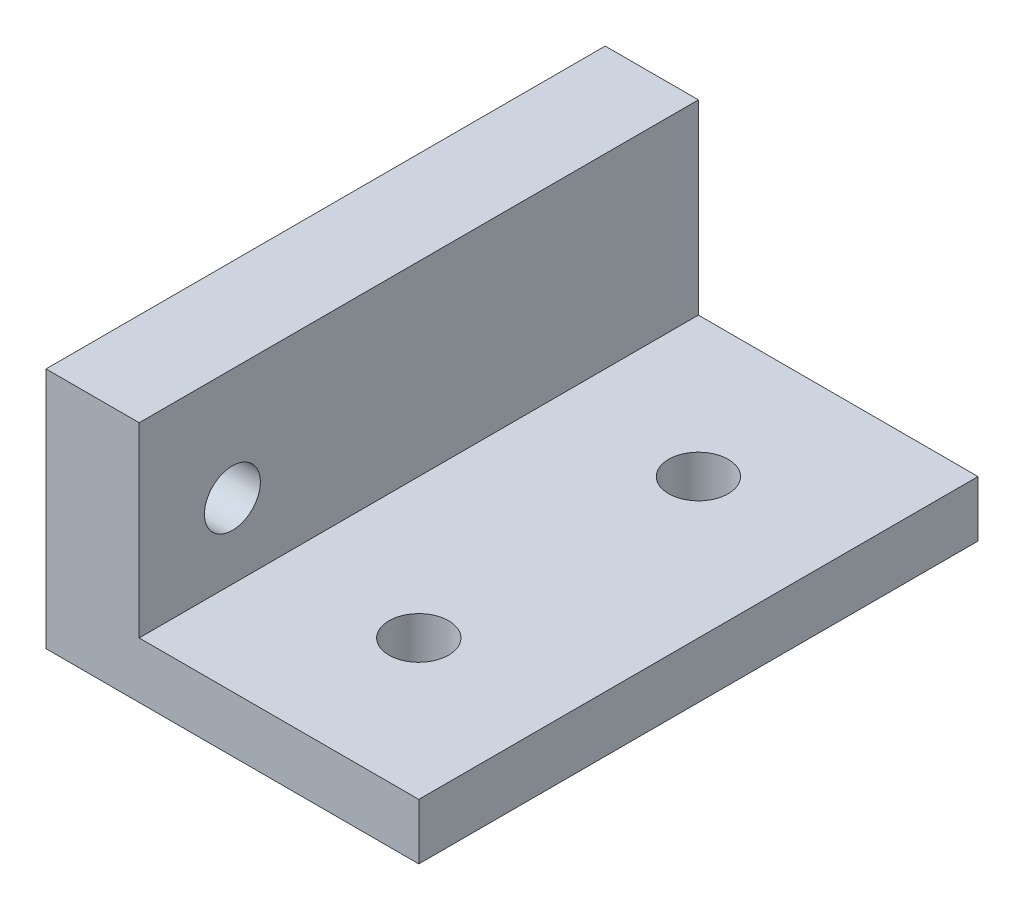
from build123d import *

# Parameters (mm, degrees)
SKETCH1_W           = 20
SKETCH1_H           = 30
BOSS_EXTRUDE1_DEPTH = 3
SKETCH2_W           = 5
SKETCH2_H           = 30
BOSS_EXTRUDE2_DEPTH = 10
SKETCH3_R           = 1.5
CUT_EXTRUDE1_DEPTH  = 10
SKETCH4_R           = 1.6
CUT_EXTRUDE2_DEPTH  = 4


with BuildPart() as part:
    # Sketch1 → Boss-Extrude1 (new body)
    with BuildSketch(Plane(origin=(0, 0, 0), x_dir=(1, 0, 0), z_dir=(0, 1, 0))):
        Rectangle(SKETCH1_W, SKETCH1_H)
    extrude(amount=BOSS_EXTRUDE1_DEPTH)

    # Sketch2 → Boss-Extrude2 (add)
    with BuildSketch(Plane(origin=(0, 3, 0), x_dir=(1, 0, 0), z_dir=(0, 1, 0))):
        with Locations((-7.5, 0)):
            Rectangle(SKETCH2_W, SKETCH2_H)
    extrude(amount=BOSS_EXTRUDE2_DEPTH)

    # Sketch3 → Cut-Extrude1 (cut)
    with BuildSketch(Plane.ZY.offset(10)):
        with Locations((10, 7)):
            Circle(SKETCH3_R)
    extrude(amount=-CUT_EXTRUDE1_DEPTH, mode=Mode.SUBTRACT)

    # Sketch4 → Cut-Extrude2 (cut, through all)
    with BuildSketch(Plane(origin=(0, 3, 0), x_dir=(1, 0, 0), z_dir=(0, 1, 0))):
        with Locations((2.5, -7.5)):
            Circle(SKETCH4_R)
        with Locations((2.5, 7.5)):
            Circle(SKETCH4_R)
    extrude(amount=-CUT_EXTRUDE2_DEPTH, mode=Mode.SUBTRACT)


solid = part.part
